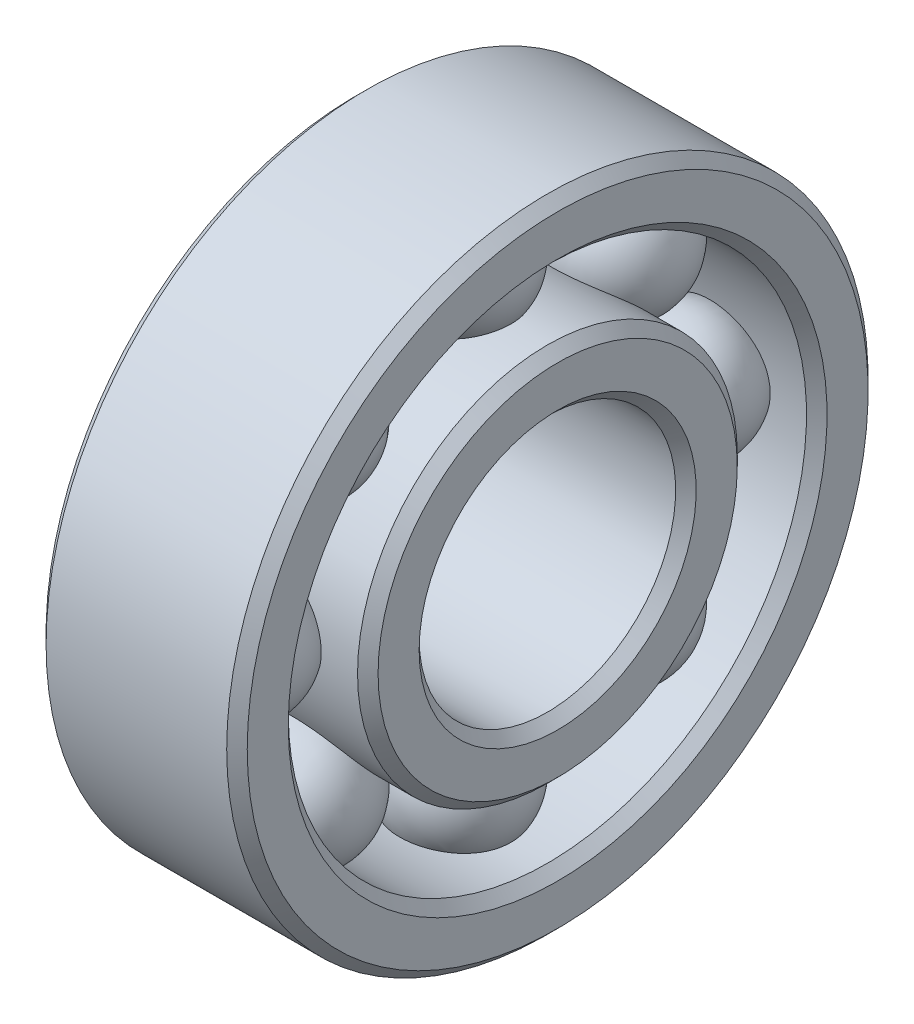
from build123d import *

# Parameters (mm, degrees)
SKETCH1_W         = 4.9784
SKETCH1_H         = 1.524
CIRPATTERN1_COUNT = 8
CHAMFER1_SIZE     = 0.254


with BuildPart() as part:
    # Sketch1 → Revolve1 (revolve)
    with BuildSketch(Plane.XY):
        with Locations((0, 3.937)):
            Rectangle(SKETCH1_W, SKETCH1_H)
        with Locations((0, 7.1755)):
            Rectangle(SKETCH1_W, SKETCH1_H)
    revolve(axis=Axis((0, 0, 0), (1, 0, 0)))

    # Sketch2 → Revolve2 (revolve)
    with BuildSketch(Plane.XY):
        with BuildLine():
            Line((-1.5875, 5.55625), (1.5875, 5.55625))
            ThreePointArc((1.5875, 5.55625), (0, 7.14375), (-1.5875, 5.55625))
        make_face()
    revolve2 = revolve(axis=Axis((-1.5875, 5.55625, 0), (1, 0, 0)))

    # CirPattern1: Revolve2 ×8 about axis
    cirpattern1_axis = Axis((0, 0, 0), (1, 0, 0))
    for i in range(1, CIRPATTERN1_COUNT):
        add(revolve2.rotate(cirpattern1_axis, i * 360 / CIRPATTERN1_COUNT))

    # Chamfer1
    chamfer1_edges = [part.edges().sort_by_distance(p)[0] for p in [
        (-2.4892, -6.4135, 0),
        (-2.4892, -7.9375, 0),
        (2.4892, -6.4135, 0),
        (2.4892, -7.9375, 0),
        (-2.4892, -3.175, 0),
        (2.4892, -3.175, 0),
        (2.4892, -4.699, 0),
        (-2.4892, -4.699, 0),
    ]]
    chamfer(chamfer1_edges, length=CHAMFER1_SIZE)


solid = part.part
